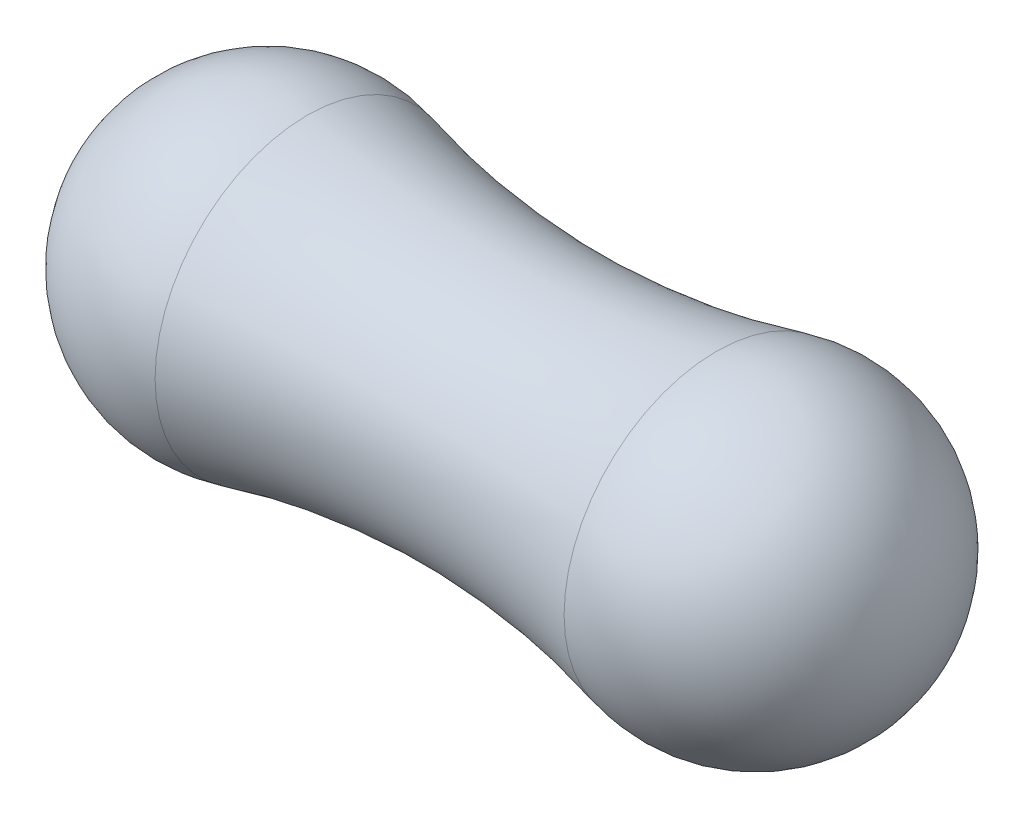
from build123d import *


with BuildPart() as part:
    # Sketch1 → Revolve1 (revolve)
    with BuildSketch(Plane(origin=(0, 0, 0), x_dir=(1, 0, 0), z_dir=(0, 1, 0))):
        with BuildLine():
            Line((-2.54, 0), (2.54, 0))
            ThreePointArc((2.54, 0), (2.15384681, 0.787229361), (1.294958704, 0.963738782))
            ThreePointArc((1.294958704, 0.963738782), (0, 0.798817365), (-1.294958704, 0.963738782))
            ThreePointArc((-1.294958704, 0.963738782), (-2.15384681, 0.787229361), (-2.54, 0))
        make_face()
    revolve(axis=Axis((2.54, 0, 0), (1, 0, 0)))


solid = part.part
